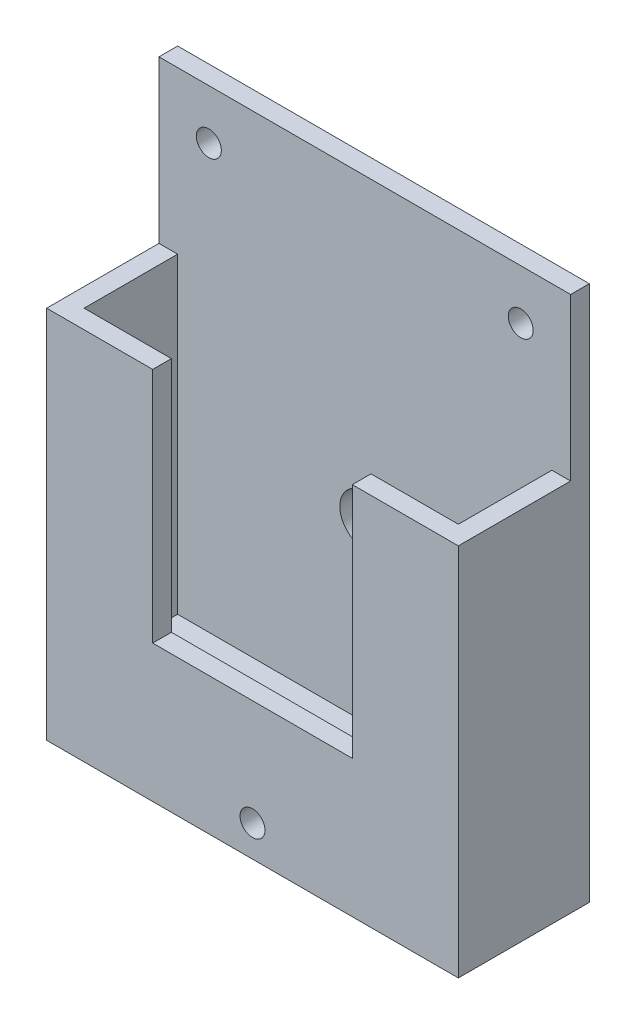
from build123d import *

# Parameters (mm, degrees)
BOSS_EXTRUDE1_DEPTH = 66
CUT_EXTRUDE1_START  = -3
SKETCH2_W           = 15
SKETCH2_H           = 50
CUT_EXTRUDE1_DEPTH  = 60
SKETCH3_W           = 32
SKETCH3_H           = 38
CUT_EXTRUDE2_DEPTH  = 19
SKETCH4_R           = 4
SKETCH4_R_2         = 2
CUT_EXTRUDE3_DEPTH  = 22


with BuildPart() as part:
    # Sketch1 → Boss-Extrude1 (new body)
    with BuildSketch(Plane(origin=(0, 0, 0), x_dir=(0, 0, -1), z_dir=(1, 0, 0))):
        Polygon((-3, -25.9), (-21, -25.9), (-21, -85.9), (0, -85.9), (0, 0), (-3, 0), align=None)
    extrude(amount=-BOSS_EXTRUDE1_DEPTH)

    # Sketch2 → Cut-Extrude1 (cut)
    with BuildSketch(Plane(origin=(0, 0, 0), x_dir=(0, 0, -1), z_dir=(1, 0, 0)).offset(CUT_EXTRUDE1_START)):
        with Locations((-10.5, -50.9)):
            Rectangle(SKETCH2_W, SKETCH2_H)
    extrude(amount=-CUT_EXTRUDE1_DEPTH, mode=Mode.SUBTRACT)

    # Sketch3 → Cut-Extrude2 (cut, through all)
    with BuildSketch(Plane.XY.offset(3)):
        with Locations((-33, -44.9)):
            Rectangle(SKETCH3_W, SKETCH3_H)
    extrude(amount=CUT_EXTRUDE2_DEPTH, mode=Mode.SUBTRACT)

    # Sketch4 → Cut-Extrude3 (cut, through all)
    with BuildSketch(Plane(origin=(0, 0, 0), x_dir=(-1, 0, 0), z_dir=(0, 0, -1))):
        with Locations((33, -47.9)):
            Circle(SKETCH4_R)
        with Locations((33, -80.9)):
            Circle(SKETCH4_R_2)
        with Locations((58, -8)):
            Circle(SKETCH4_R_2)
        with Locations((8, -8)):
            Circle(SKETCH4_R_2)
    extrude(amount=-CUT_EXTRUDE3_DEPTH, mode=Mode.SUBTRACT)


solid = part.part
